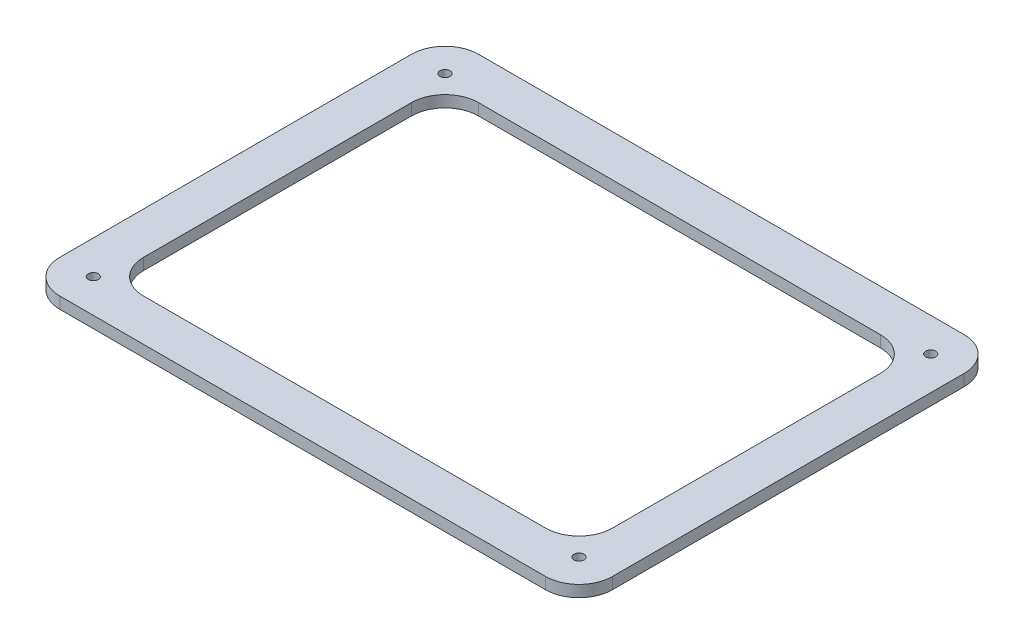
from build123d import *

# Parameters (mm, degrees)
SKETCH1_W           = 330
SKETCH1_H           = 250
BOSS_EXTRUDE1_DEPTH = 6.9
SKETCH2_R           = 3
CUT_EXTRUDE1_DEPTH  = 7.9
SKETCH3_W           = 280
SKETCH3_H           = 200
CUT_EXTRUDE2_DEPTH  = 7.9
FILLET1_R           = 20
FILLET2_R           = 20


with BuildPart() as part:
    # Sketch1 → Boss-Extrude1 (new body)
    with BuildSketch(Plane(origin=(0, 0, 0), x_dir=(1, 0, 0), z_dir=(0, 1, 0))):
        Rectangle(SKETCH1_W, SKETCH1_H)
    extrude(amount=BOSS_EXTRUDE1_DEPTH)

    # Sketch2 → Cut-Extrude1 (cut, through all)
    with BuildSketch(Plane(origin=(0, 6.9, 0), x_dir=(1, 0, 0), z_dir=(0, 1, 0))):
        with Locations((-145, 105)):
            Circle(SKETCH2_R)
        with Locations((145, 105)):
            Circle(SKETCH2_R)
        with Locations((145, -105)):
            Circle(SKETCH2_R)
        with Locations((-145, -105)):
            Circle(SKETCH2_R)
    extrude(amount=-CUT_EXTRUDE1_DEPTH, mode=Mode.SUBTRACT)

    # Sketch3 → Cut-Extrude2 (cut, through all)
    with BuildSketch(Plane(origin=(0, 6.9, 0), x_dir=(1, 0, 0), z_dir=(0, 1, 0))):
        Rectangle(SKETCH3_W, SKETCH3_H)
    extrude(amount=-CUT_EXTRUDE2_DEPTH, mode=Mode.SUBTRACT)

    # Fillet1
    fillet1_edges = [part.edges().sort_by_distance(p)[0] for p in [
        (-165, 3.45, -125),
        (165, 3.45, -125),
        (165, 3.45, 125),
        (-165, 3.45, 125),
    ]]
    fillet(fillet1_edges, radius=FILLET1_R)

    # Fillet2
    fillet2_edges = [part.edges().sort_by_distance(p)[0] for p in [
        (-140, 3.45, 100),
        (-140, 3.45, -100),
        (140, 3.45, -100),
        (140, 3.45, 100),
    ]]
    fillet(fillet2_edges, radius=FILLET2_R)


solid = part.part
